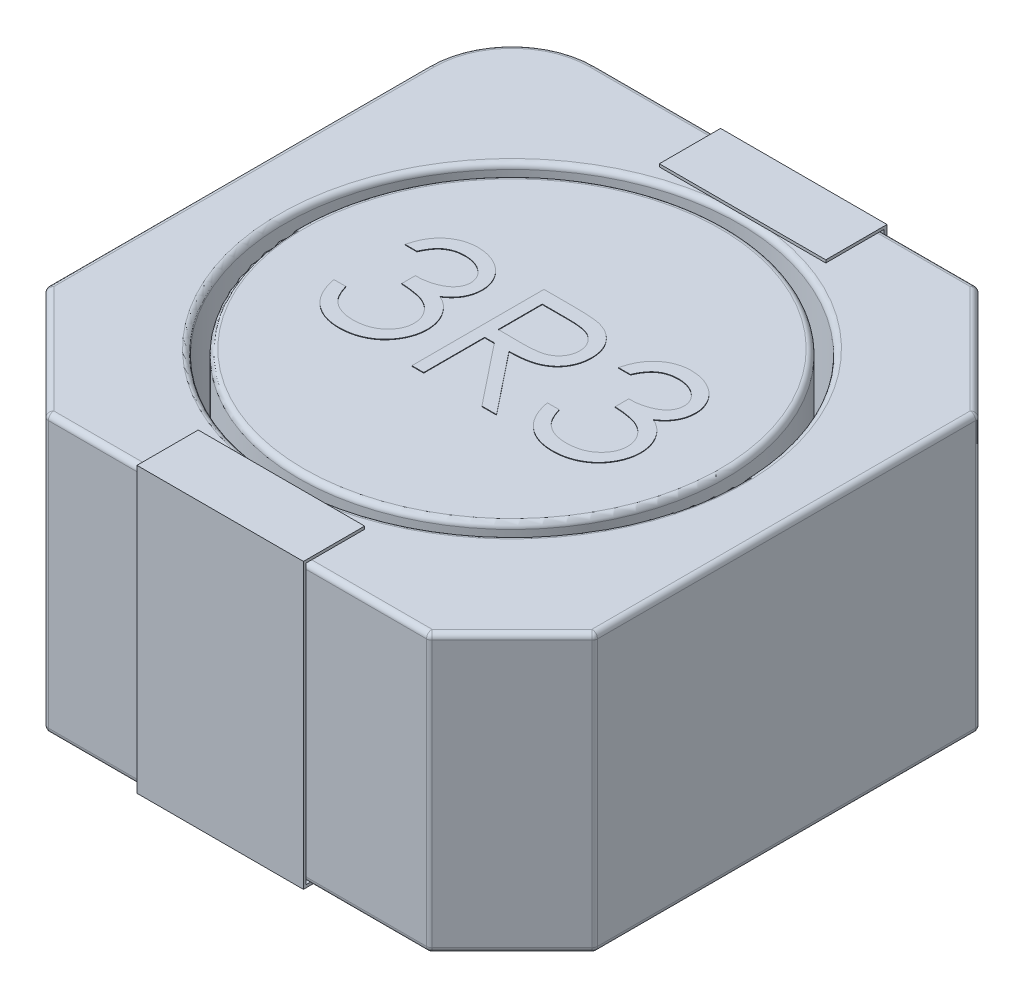
from build123d import *

# Parameters (mm, degrees)
EXTRUDE_1_DEPTH     = 5
SKETCH_2_R          = 4.1
SKETCH_2_R_2        = 3.85
CUT_EXTRUDE_1_DEPTH = 3.5
EXTRUDE_2_DEPTH     = 1.5
EXTRUDE_2_2_DEPTH   = 1.5
FILLET_1_R          = 0.1
FILLET_2_R          = 0.1
FILLET_3_R          = 0.1
FILLET_4_R          = 0.1
FILLET_5_R          = 0.1
EXTRUDE_3_DEPTH     = 0.01


with BuildPart() as part:
    # 草图1 → 凸台-拉伸1 (new body)
    with BuildSketch(Plane(origin=(0, 0, 0), x_dir=(1, 0, 0), z_dir=(0, 1, 0))):
        with BuildLine():
            Line((5.2, -3.7), (3.7, -5.2))
            Line((3.7, -5.2), (-3.2, -5.2))
            Line((-3.2, -5.2), (-5.2, -3.2))
            Line((-5.2, -3.2), (-5.2, 3.7))
            ThreePointArc((-5.2, 3.7), (-4.760660172, 4.760660172), (-3.7, 5.2))
            Line((-3.7, 5.2), (3.2, 5.2))
            Line((3.2, 5.2), (5.2, 3.2))
            Line((5.2, 3.2), (5.2, -3.7))
        make_face()
    extrude(amount=EXTRUDE_1_DEPTH)

    # 草图2 → 切除-拉伸1 (cut)
    with BuildSketch(Plane(origin=(0, 5, 0), x_dir=(1, 0, 0), z_dir=(0, 1, 0))):
        Circle(SKETCH_2_R)
        Circle(SKETCH_2_R_2, mode=Mode.SUBTRACT)
    extrude(amount=-CUT_EXTRUDE_1_DEPTH, mode=Mode.SUBTRACT)

    # 圆角1
    fillet_1_edges = [part.edges().sort_by_distance(p)[0] for p in [
        (-4.2, 5, 4.2),
        (0.25, 5, 5.2),
        (4.45, 5, 4.45),
        (5.2, 5, 0.25),
        (4.2, 5, -4.2),
        (-0.25, 5, -5.2),
        (-4.1, 5, 0),
        (-4.760660172, 5, -4.760660172),
        (-5.2, 5, -0.25),
    ]]
    fillet(fillet_1_edges, radius=FILLET_1_R)

    # 圆角2
    fillet_2_edges = [part.edges().sort_by_distance(p)[0] for p in [
        (-3.85, 5, 0),
    ]]
    fillet(fillet_2_edges, radius=FILLET_2_R)

    # 圆角3
    fillet_3_edges = [part.edges().sort_by_distance(p)[0] for p in [
        (-5.2, 0, -0.25),
        (-4.760660172, 0, -4.760660172),
        (-0.25, 0, -5.2),
        (4.2, 0, -4.2),
        (5.2, 0, 0.25),
        (4.45, 0, 4.45),
        (0.25, 0, 5.2),
        (-4.2, 0, 4.2),
    ]]
    fillet(fillet_3_edges, radius=FILLET_3_R)

    # 圆角4
    fillet_4_edges = [part.edges().sort_by_distance(p)[0] for p in [
        (5.2, 2.5, 3.7),
        (3.7, 2.5, 5.2),
        (-3.2, 2.5, 5.2),
        (-5.2, 2.5, 3.2),
        (3.687283915, 4.972093128, 5.169300656),
        (-3.187283915, 4.972093128, 5.169300656),
        (5.169300656, 4.972093128, 3.687283915),
        (-5.169300656, 4.972093128, 3.187283915),
        (5.169300656, 0.027906872, 3.687283915),
        (3.687283915, 0.027906872, 5.169300656),
        (-3.187283915, 0.027906872, 5.169300656),
        (-5.169300656, 0.027906872, 3.187283915),
    ]]
    fillet(fillet_4_edges, radius=FILLET_4_R)

    # 圆角5
    fillet_5_edges = [part.edges().sort_by_distance(p)[0] for p in [
        (3.2, 2.5, -5.2),
        (5.2, 2.5, -3.2),
        (5.169300656, 4.972093128, -3.187283915),
        (3.187283915, 4.972093128, -5.169300656),
        (5.169300656, 0.027906872, -3.187283915),
        (3.187283915, 0.027906872, -5.169300656),
    ]]
    fillet(fillet_5_edges, radius=FILLET_5_R)

    # 草图4 → 凸台-拉伸3 (add)
    with BuildSketch(Plane(origin=(0, 5, 0), x_dir=(1, 0, 0), z_dir=(0, 1, 0))):
        with BuildLine():
            Line((-2.368651512, 0.655484103), (-2.582353435, 0.655484103))
            add(Edge.make_bspline(
                [(-2.582353435, 0.655484103), (-2.576563902, 0.679454775), (-2.565245837, 0.726315479), (-2.541639095, 0.793267562), (-2.515922102, 0.856624815), (-2.4850413, 0.915200893), (-2.451357666, 0.970173004), (-2.412765957, 1.020294319), (-2.371046646, 1.066839569), (-2.324901457, 1.108146253), (-2.276508564, 1.145550744), (-2.225186082, 1.177442524), (-2.171966577, 1.20487735), (-2.116481321, 1.227478972), (-2.058565122, 1.244505266), (-1.998741575, 1.256858378), (-1.936853908, 1.264880547), (-1.894843493, 1.265663477), (-1.873511789, 1.266061026)],
                knots=[0, 0, 0, 0, 7.3931e-05, 0.000144529, 0.000212742, 0.000278882, 0.000342945, 0.000405913, 0.000468387, 0.000530188, 0.000591439, 0.00065166, 0.000711181, 0.000770884, 0.000831103, 0.000892006, 0.000954012, 0.001017976, 0.001017976, 0.001017976, 0.001017976], degree=3))
            add(Edge.make_bspline(
                [(-1.873511789, 1.266061026), (-1.842431209, 1.265122657), (-1.780948007, 1.263266387), (-1.69062172, 1.246315673), (-1.603517759, 1.219492502), (-1.520589538, 1.182430913), (-1.443560569, 1.136719544), (-1.375023985, 1.082314965), (-1.315908766, 1.020266868), (-1.266314555, 0.951732749), (-1.227483172, 0.878488554), (-1.198849407, 0.803104876), (-1.181417513, 0.725760534), (-1.179158349, 0.673538171), (-1.178026512, 0.647374879)],
                knots=[0, 0, 0, 0, 9.3165e-05, 0.000184299, 0.000274676, 0.00036607, 0.000456139, 0.000542705, 0.000627729, 0.00071246, 0.000795685, 0.000875689, 0.000953816, 0.001032256, 0.001032256, 0.001032256, 0.001032256], degree=3))
            add(Edge.make_bspline(
                [(-1.178026512, 0.647374879), (-1.17881817, 0.622197041), (-1.180367321, 0.572927921), (-1.193521145, 0.500999546), (-1.215657424, 0.433207671), (-1.246320959, 0.369266916), (-1.286014049, 0.309582695), (-1.334096724, 0.254020723), (-1.390908356, 0.202334563), (-1.433960633, 0.172725779), (-1.45612522, 0.1574823)],
                knots=[0, 0, 0, 0, 7.549e-05, 0.000147723, 0.00021847, 0.000288876, 0.000359789, 0.000432846, 0.000508829, 0.000589457, 0.000589457, 0.000589457, 0.000589457], degree=3))
            add(Edge.make_bspline(
                [(-1.45612522, 0.1574823), (-1.43079433, 0.145250723), (-1.38060651, 0.12101643), (-1.312196239, 0.073489567), (-1.250094685, 0.018614445), (-1.215461976, -0.024209039), (-1.198061068, -0.045725332)],
                knots=[0, 0, 0, 0, 8.4271e-05, 0.000166965, 0.000249046, 0.000331932, 0.000331932, 0.000331932, 0.000331932], degree=3))
            add(Edge.make_bspline(
                [(-1.198061068, -0.045725332), (-1.18660294, -0.061412838), (-1.16387432, -0.092530956), (-1.13581943, -0.142561989), (-1.110367872, -0.193147555), (-1.090535312, -0.245643509), (-1.07517702, -0.299441398), (-1.064198755, -0.3546336), (-1.05737876, -0.411265183), (-1.056402071, -0.449577781), (-1.055911128, -0.468836059)],
                knots=[0, 0, 0, 0, 5.8227e-05, 0.0001155, 0.00017182, 0.000227986, 0.00028355, 0.000339493, 0.000396649, 0.000454416, 0.000454416, 0.000454416, 0.000454416], degree=3))
            add(Edge.make_bspline(
                [(-1.055911128, -0.468836059), (-1.057132038, -0.502180173), (-1.059568112, -0.568711483), (-1.081342313, -0.667005892), (-1.115097036, -0.763089671), (-1.163032915, -0.854988802), (-1.221453488, -0.940972597), (-1.290956953, -1.017904872), (-1.370753599, -1.084034637), (-1.459748157, -1.139286595), (-1.556166417, -1.183453967), (-1.659291954, -1.214109121), (-1.767638866, -1.234074881), (-1.841938831, -1.236215876), (-1.879712961, -1.237304358)],
                knots=[0, 0, 0, 0, 9.9919e-05, 0.000199368, 0.000300604, 0.000404715, 0.000509373, 0.0006117, 0.000714673, 0.000819238, 0.000925117, 0.001031803, 0.001141284, 0.001254506, 0.001254506, 0.001254506, 0.001254506], degree=3))
            add(Edge.make_bspline(
                [(-1.879712961, -1.237304358), (-1.905171449, -1.236713663), (-1.955265264, -1.235551372), (-2.028909502, -1.227605752), (-2.099205158, -1.213093731), (-2.166247277, -1.193565232), (-2.230095418, -1.168805851), (-2.290554747, -1.137972951), (-2.347997228, -1.101702089), (-2.4018808, -1.059565131), (-2.45219904, -1.012429076), (-2.497614732, -0.959457143), (-2.538885056, -0.901628552), (-2.574904958, -0.838271615), (-2.607315099, -0.77020511), (-2.633972143, -0.696557471), (-2.657434646, -0.617987092), (-2.668343128, -0.563233486), (-2.673939974, -0.535140897)],
                knots=[0, 0, 0, 0, 7.6376e-05, 0.000150282, 0.000221848, 0.000291435, 0.000359554, 0.000426967, 0.000494723, 0.000563043, 0.000631881, 0.000701213, 0.000772025, 0.000844681, 0.000919578, 0.000997909, 0.001079421, 0.00116531, 0.00116531, 0.00116531, 0.00116531], degree=3))
            Line((-2.673939974, -0.535140897), (-2.460238051, -0.535140897))
            add(Edge.make_bspline(
                [(-2.460238051, -0.535140897), (-2.45467049, -0.55347585), (-2.443841101, -0.589138928), (-2.425407301, -0.640465279), (-2.404405852, -0.687517454), (-2.381876126, -0.730640614), (-2.358214361, -0.770259445), (-2.331738314, -0.805326324), (-2.304408949, -0.837381488), (-2.283808175, -0.855441304), (-2.273725881, -0.864280019)],
                knots=[0, 0, 0, 0, 5.7482e-05, 0.000111807, 0.000163485, 0.000211918, 0.000257731, 0.000301712, 0.000343624, 0.000383798, 0.000383798, 0.000383798, 0.000383798], degree=3))
            add(Edge.make_bspline(
                [(-2.273725881, -0.864280019), (-2.26039321, -0.874559082), (-2.233769024, -0.895085479), (-2.190383852, -0.921280337), (-2.144755778, -0.943977749), (-2.095896151, -0.961315763), (-2.044859317, -0.975996279), (-1.990820341, -0.985603275), (-1.934255981, -0.992194691), (-1.895633628, -0.99277635), (-1.875896855, -0.993073589)],
                knots=[0, 0, 0, 0, 5.0469e-05, 0.000100782, 0.000151769, 0.000203078, 0.000256087, 0.000310912, 0.00036754, 0.000426721, 0.000426721, 0.000426721, 0.000426721], degree=3))
            add(Edge.make_bspline(
                [(-1.875896855, -0.993073589), (-1.853612775, -0.992654553), (-1.810038182, -0.991835166), (-1.746455501, -0.984299729), (-1.685966684, -0.973325287), (-1.629243318, -0.956375562), (-1.575542384, -0.935433589), (-1.525616654, -0.909138871), (-1.478810732, -0.878288265), (-1.435724119, -0.843223231), (-1.396980836, -0.804836464), (-1.36286806, -0.764686499), (-1.333868067, -0.722942622), (-1.310474954, -0.679373829), (-1.292002883, -0.63416054), (-1.279427705, -0.587175872), (-1.270684085, -0.538804339), (-1.269972015, -0.50592338), (-1.269613051, -0.489347627)],
                knots=[0, 0, 0, 0, 6.6824e-05, 0.000130669, 0.000191854, 0.000251023, 0.000307979, 0.000364521, 0.000419955, 0.000475904, 0.000530885, 0.00058335, 0.000633762, 0.000683063, 0.000731428, 0.000779917, 0.000828773, 0.00087844, 0.00087844, 0.00087844, 0.00087844], degree=3))
            add(Edge.make_bspline(
                [(-1.269613051, -0.489347627), (-1.270654202, -0.46716027), (-1.272731325, -0.422895957), (-1.288589483, -0.357773821), (-1.314673604, -0.295028964), (-1.35119008, -0.2357319), (-1.39564171, -0.180775438), (-1.447597119, -0.13174109), (-1.507487753, -0.091280189), (-1.5626102, -0.063325228), (-1.611436137, -0.044250004), (-1.653220532, -0.031544358), (-1.699999579, -0.020785425), (-1.751207577, -0.010775826), (-1.807230372, -0.002256837), (-1.868006974, 0.004847327), (-1.933549697, 0.010531739), (-1.978923508, 0.013070216), (-2.002305358, 0.014378334)],
                knots=[0, 0, 0, 0, 6.6512e-05, 0.000132693, 0.000199842, 0.000269625, 0.000340845, 0.00041138, 0.000483093, 0.000556905, 0.000596324, 0.000640233, 0.000687786, 0.000740268, 0.000796736, 0.000857737, 0.000923814, 0.000994066, 0.000994066, 0.000994066, 0.000994066], degree=3))
            Line((-2.002305358, 0.014378334), (-2.002305358, 0.258609103))
            add(Edge.make_bspline(
                [(-2.002305358, 0.258609103), (-1.972845101, 0.259109032), (-1.915139694, 0.26008827), (-1.830847319, 0.271931934), (-1.750243155, 0.288315362), (-1.675113532, 0.313410466), (-1.606636461, 0.342557168), (-1.547227946, 0.376474475), (-1.497720297, 0.414176295), (-1.458354104, 0.456244553), (-1.428738682, 0.501362469), (-1.407085094, 0.54838648), (-1.394294157, 0.597728743), (-1.392586687, 0.631402794), (-1.391728435, 0.648328905)],
                knots=[0, 0, 0, 0, 8.8311e-05, 0.000172979, 0.000254936, 0.000334734, 0.000410148, 0.000477894, 0.000539436, 0.000596138, 0.000649853, 0.000700661, 0.000750872, 0.000801617, 0.000801617, 0.000801617, 0.000801617], degree=3))
            add(Edge.make_bspline(
                [(-1.391728435, 0.648328905), (-1.392010383, 0.660764299), (-1.392571304, 0.685503927), (-1.399645166, 0.721647947), (-1.410275094, 0.756686983), (-1.424888981, 0.790472029), (-1.444449384, 0.822768769), (-1.467857743, 0.853852551), (-1.495730683, 0.883545908), (-1.527670353, 0.911223054), (-1.561968384, 0.937599982), (-1.599557964, 0.95999301), (-1.639305703, 0.979141704), (-1.68125561, 0.994932454), (-1.725543819, 1.006811006), (-1.771962244, 1.015339855), (-1.820599401, 1.020672259), (-1.853781597, 1.021439985), (-1.870649709, 1.021830257)],
                knots=[0, 0, 0, 0, 3.7256e-05, 7.4119e-05, 0.000110031, 0.000146987, 0.000184209, 0.000223038, 0.000263537, 0.000306122, 0.000349721, 0.000393161, 0.000437111, 0.000481942, 0.000527419, 0.000574479, 0.000623416, 0.000674016, 0.000674016, 0.000674016, 0.000674016], degree=3))
            add(Edge.make_bspline(
                [(-1.870649709, 1.021830257), (-1.897763076, 1.020883634), (-1.950721788, 1.019034659), (-2.027068008, 1.002840109), (-2.098042412, 0.977001448), (-2.152293184, 0.946158805), (-2.192354364, 0.915712528), (-2.220981709, 0.889122547), (-2.249094414, 0.859572715), (-2.27484299, 0.825242999), (-2.300882964, 0.788458272), (-2.32458971, 0.747348589), (-2.347626393, 0.702986313), (-2.361507414, 0.671624819), (-2.368651512, 0.655484103)],
                knots=[0, 0, 0, 0, 8.1262e-05, 0.000158723, 0.000232978, 0.000307113, 0.000344894, 0.00038372, 0.000424218, 0.000467059, 0.000512313, 0.000559354, 0.000609276, 0.000662216, 0.000662216, 0.000662216, 0.000662216], degree=3))
        make_face()
        with BuildLine():
            Line((-0.628507282, 1.205003334), (-0.151971074, 1.205003334))
            add(Edge.make_bspline(
                [(-0.151971074, 1.205003334), (-0.120170413, 1.20489748), (-0.059109622, 1.204694229), (0.028366121, 1.203560915), (0.107850271, 1.200312648), (0.179301269, 1.197517344), (0.242717804, 1.192420148), (0.298294335, 1.187548351), (0.345774894, 1.181170913), (0.374517161, 1.175248117), (0.38753088, 1.172566435)],
                knots=[0, 0, 0, 0, 9.5404e-05, 0.000183186, 0.000262422, 0.000334052, 0.000397674, 0.000453255, 0.000501422, 0.000541275, 0.000541275, 0.000541275, 0.000541275], degree=3))
            add(Edge.make_bspline(
                [(0.38753088, 1.172566435), (0.404952529, 1.168261975), (0.439424177, 1.159744881), (0.489056276, 1.141742902), (0.536350843, 1.120910622), (0.58111142, 1.096442448), (0.623113806, 1.06815675), (0.662791085, 1.036541831), (0.700323302, 1.001770678), (0.73419259, 0.962966616), (0.766127909, 0.92225642), (0.793062314, 0.878234757), (0.816280508, 0.832200753), (0.834766164, 0.783686242), (0.849650999, 0.733161715), (0.860146351, 0.680169516), (0.866440463, 0.624951067), (0.867081261, 0.587287918), (0.86740618, 0.568190684)],
                knots=[0, 0, 0, 0, 5.3803e-05, 0.000106459, 0.000158137, 0.000208732, 0.000259271, 0.000309854, 0.000360814, 0.00041251, 0.000464222, 0.000515847, 0.000567046, 0.000618691, 0.000671372, 0.000724883, 0.000780563, 0.000837836, 0.000837836, 0.000837836, 0.000837836], degree=3))
            add(Edge.make_bspline(
                [(0.86740618, 0.568190684), (0.866406737, 0.536462157), (0.864456564, 0.474551584), (0.846273949, 0.38470302), (0.816490281, 0.30089029), (0.7754489, 0.223218924), (0.723184221, 0.153202931), (0.66037039, 0.091705139), (0.586972365, 0.040242984), (0.518644563, 0.004556344), (0.458287223, -0.018298831), (0.408598487, -0.034379997), (0.35439649, -0.046804655), (0.296200553, -0.057935388), (0.233768495, -0.066338951), (0.16724995, -0.072493866), (0.096597479, -0.076340639), (0.048061434, -0.076913503), (0.023092779, -0.077208204)],
                knots=[0, 0, 0, 0, 9.5098e-05, 0.000185561, 0.000273673, 0.000361163, 0.000448075, 0.000534767, 0.000623712, 0.000716091, 0.000765168, 0.000817215, 0.000872634, 0.000931855, 0.000994931, 0.001061525, 0.001132226, 0.001207131, 0.001207131, 0.001207131, 0.001207131], degree=3))
            Line((0.023092779, -0.077208204), (0.897935026, -1.176246666))
            Line((0.897935026, -1.176246666), (0.633669702, -1.176246666))
            Line((0.633669702, -1.176246666), (-0.241172546, -0.077208204))
            Line((-0.241172546, -0.077208204), (-0.414805358, -0.077208204))
            Line((-0.414805358, -0.077208204), (-0.414805358, -1.176246666))
            Line((-0.414805358, -1.176246666), (-0.628507282, -1.176246666))
            Line((-0.628507282, -1.176246666), (-0.628507282, 1.205003334))
        make_face()
        with BuildLine():
            Line((-0.414805358, 0.960772565), (-0.414805358, 0.167022565))
            Line((-0.414805358, 0.167022565), (0.021184726, 0.163683472))
            add(Edge.make_bspline(
                [(0.021184726, 0.163683472), (0.041541038, 0.163674467), (0.080997369, 0.163657011), (0.138079785, 0.166374205), (0.191229361, 0.169465284), (0.240242802, 0.174193321), (0.285142002, 0.180286649), (0.325904521, 0.187908679), (0.362596897, 0.196788743), (0.405390367, 0.210533063), (0.453176293, 0.232308587), (0.505108947, 0.263989756), (0.549333751, 0.303837675), (0.586697511, 0.349403544), (0.616721285, 0.399502492), (0.637888594, 0.453533986), (0.651320505, 0.510133984), (0.652904748, 0.549035518), (0.653704257, 0.568667697)],
                knots=[0, 0, 0, 0, 6.106e-05, 0.000118351, 0.000171404, 0.000220768, 0.000266034, 0.000307292, 0.000345124, 0.000379216, 0.000441986, 0.000502207, 0.000560994, 0.000619628, 0.000678448, 0.000735404, 0.000793147, 0.000851976, 0.000851976, 0.000851976, 0.000851976], degree=3))
            add(Edge.make_bspline(
                [(0.653704257, 0.568667697), (0.652886385, 0.58781742), (0.651265662, 0.625765182), (0.638033553, 0.681320364), (0.615657028, 0.733753414), (0.585502077, 0.782851037), (0.548763366, 0.827418332), (0.50568464, 0.865550413), (0.457443784, 0.897016566), (0.412355701, 0.9171241), (0.372055281, 0.929452072), (0.337064745, 0.938127417), (0.297528186, 0.945097315), (0.253253633, 0.950681728), (0.204430094, 0.955481609), (0.150810705, 0.958714516), (0.092751217, 0.960628949), (0.05251018, 0.960723579), (0.031679017, 0.960772565)],
                knots=[0, 0, 0, 0, 5.7402e-05, 0.000113751, 0.000170185, 0.00022778, 0.000286046, 0.000342812, 0.000399705, 0.000458213, 0.000490197, 0.000526062, 0.000566296, 0.000610553, 0.000659916, 0.000713446, 0.000771673, 0.000834163, 0.000834163, 0.000834163, 0.000834163], degree=3))
            Line((0.031679017, 0.960772565), (-0.414805358, 0.960772565))
        make_face(mode=Mode.SUBTRACT)
        with BuildLine():
            Line((1.477983103, 0.655484103), (1.26428118, 0.655484103))
            add(Edge.make_bspline(
                [(1.26428118, 0.655484103), (1.270070714, 0.679454775), (1.281388778, 0.726315479), (1.30499552, 0.793267562), (1.330712513, 0.856624815), (1.361593315, 0.915200893), (1.395276949, 0.970173004), (1.433868658, 1.020294319), (1.475587969, 1.066839569), (1.521733158, 1.108146253), (1.570126051, 1.145550744), (1.621448534, 1.177442524), (1.674668038, 1.20487735), (1.730153295, 1.227478972), (1.788069494, 1.244505266), (1.847893041, 1.256858378), (1.909780708, 1.264880547), (1.951791122, 1.265663477), (1.973122827, 1.266061026)],
                knots=[0, 0, 0, 0, 7.3931e-05, 0.000144529, 0.000212742, 0.000278882, 0.000342945, 0.000405913, 0.000468387, 0.000530188, 0.000591439, 0.00065166, 0.000711181, 0.000770884, 0.000831103, 0.000892006, 0.000954012, 0.001017976, 0.001017976, 0.001017976, 0.001017976], degree=3))
            add(Edge.make_bspline(
                [(1.973122827, 1.266061026), (2.004203406, 1.265122657), (2.065686609, 1.263266387), (2.156012896, 1.246315673), (2.243116857, 1.219492502), (2.326045077, 1.182430913), (2.403074046, 1.136719544), (2.471610631, 1.082314965), (2.53072585, 1.020266868), (2.58032006, 0.951732749), (2.619151443, 0.878488554), (2.647785208, 0.803104876), (2.665217102, 0.725760534), (2.667476266, 0.673538171), (2.668608103, 0.647374879)],
                knots=[0, 0, 0, 0, 9.3165e-05, 0.000184299, 0.000274676, 0.00036607, 0.000456139, 0.000542705, 0.000627729, 0.00071246, 0.000795685, 0.000875689, 0.000953816, 0.001032256, 0.001032256, 0.001032256, 0.001032256], degree=3))
            add(Edge.make_bspline(
                [(2.668608103, 0.647374879), (2.667816446, 0.622197041), (2.666267295, 0.572927921), (2.65311347, 0.500999546), (2.630977191, 0.433207671), (2.600313656, 0.369266916), (2.560620566, 0.309582695), (2.512537892, 0.254020723), (2.455726259, 0.202334563), (2.412673982, 0.172725779), (2.390509395, 0.1574823)],
                knots=[0, 0, 0, 0, 7.549e-05, 0.000147723, 0.00021847, 0.000288876, 0.000359789, 0.000432846, 0.000508829, 0.000589457, 0.000589457, 0.000589457, 0.000589457], degree=3))
            add(Edge.make_bspline(
                [(2.390509395, 0.1574823), (2.415840285, 0.145250723), (2.466028105, 0.12101643), (2.534438376, 0.073489567), (2.596539931, 0.018614445), (2.631172639, -0.024209039), (2.648573548, -0.045725332)],
                knots=[0, 0, 0, 0, 8.4271e-05, 0.000166965, 0.000249046, 0.000331932, 0.000331932, 0.000331932, 0.000331932], degree=3))
            add(Edge.make_bspline(
                [(2.648573548, -0.045725332), (2.660031675, -0.061412838), (2.682760296, -0.092530956), (2.710815186, -0.142561989), (2.736266744, -0.193147555), (2.756099304, -0.245643509), (2.771457595, -0.299441398), (2.78243586, -0.3546336), (2.789255856, -0.411265183), (2.790232544, -0.449577781), (2.790723488, -0.468836059)],
                knots=[0, 0, 0, 0, 5.8227e-05, 0.0001155, 0.00017182, 0.000227986, 0.00028355, 0.000339493, 0.000396649, 0.000454416, 0.000454416, 0.000454416, 0.000454416], degree=3))
            add(Edge.make_bspline(
                [(2.790723488, -0.468836059), (2.789502578, -0.502180173), (2.787066503, -0.568711483), (2.765292302, -0.667005892), (2.73153758, -0.763089671), (2.6836017, -0.854988802), (2.625181127, -0.940972597), (2.555677662, -1.017904872), (2.475881016, -1.084034637), (2.386886459, -1.139286595), (2.290468198, -1.183453967), (2.187342661, -1.214109121), (2.07899575, -1.234074881), (2.004695785, -1.236215876), (1.966921655, -1.237304358)],
                knots=[0, 0, 0, 0, 9.9919e-05, 0.000199368, 0.000300604, 0.000404715, 0.000509373, 0.0006117, 0.000714673, 0.000819238, 0.000925117, 0.001031803, 0.001141284, 0.001254506, 0.001254506, 0.001254506, 0.001254506], degree=3))
            add(Edge.make_bspline(
                [(1.966921655, -1.237304358), (1.941463167, -1.236713663), (1.891369351, -1.235551372), (1.817725114, -1.227605752), (1.747429458, -1.213093731), (1.680387338, -1.193565232), (1.616539198, -1.168805851), (1.556079869, -1.137972951), (1.498637388, -1.101702089), (1.444753816, -1.059565131), (1.394435576, -1.012429076), (1.349019883, -0.959457143), (1.30774956, -0.901628552), (1.271729657, -0.838271615), (1.239319516, -0.77020511), (1.212662473, -0.696557471), (1.18919997, -0.617987092), (1.178291488, -0.563233486), (1.172694642, -0.535140897)],
                knots=[0, 0, 0, 0, 7.6376e-05, 0.000150282, 0.000221848, 0.000291435, 0.000359554, 0.000426967, 0.000494723, 0.000563043, 0.000631881, 0.000701213, 0.000772025, 0.000844681, 0.000919578, 0.000997909, 0.001079421, 0.00116531, 0.00116531, 0.00116531, 0.00116531], degree=3))
            Line((1.172694642, -0.535140897), (1.386396565, -0.535140897))
            add(Edge.make_bspline(
                [(1.386396565, -0.535140897), (1.391964125, -0.55347585), (1.402793515, -0.589138928), (1.421227314, -0.640465279), (1.442228763, -0.687517454), (1.46475849, -0.730640614), (1.488420254, -0.770259445), (1.514896301, -0.805326324), (1.542225666, -0.837381488), (1.56282644, -0.855441304), (1.572908734, -0.864280019)],
                knots=[0, 0, 0, 0, 5.7482e-05, 0.000111807, 0.000163485, 0.000211918, 0.000257731, 0.000301712, 0.000343624, 0.000383798, 0.000383798, 0.000383798, 0.000383798], degree=3))
            add(Edge.make_bspline(
                [(1.572908734, -0.864280019), (1.586241405, -0.874559082), (1.612865592, -0.895085479), (1.656250763, -0.921280337), (1.701878837, -0.943977749), (1.750738464, -0.961315763), (1.801775299, -0.975996279), (1.855814274, -0.985603275), (1.912378634, -0.992194691), (1.951000988, -0.99277635), (1.970737761, -0.993073589)],
                knots=[0, 0, 0, 0, 5.0469e-05, 0.000100782, 0.000151769, 0.000203078, 0.000256087, 0.000310912, 0.00036754, 0.000426721, 0.000426721, 0.000426721, 0.000426721], degree=3))
            add(Edge.make_bspline(
                [(1.970737761, -0.993073589), (1.99302184, -0.992654553), (2.036596434, -0.991835166), (2.100179115, -0.984299729), (2.160667932, -0.973325287), (2.217391297, -0.956375562), (2.271092232, -0.935433589), (2.321017961, -0.909138871), (2.367823884, -0.878288265), (2.410910497, -0.843223231), (2.44965378, -0.804836464), (2.483766556, -0.764686499), (2.512766549, -0.722942622), (2.536159662, -0.679373829), (2.554631732, -0.63416054), (2.56720691, -0.587175872), (2.57595053, -0.538804339), (2.5766626, -0.50592338), (2.577021565, -0.489347627)],
                knots=[0, 0, 0, 0, 6.6824e-05, 0.000130669, 0.000191854, 0.000251023, 0.000307979, 0.000364521, 0.000419955, 0.000475904, 0.000530885, 0.00058335, 0.000633762, 0.000683063, 0.000731428, 0.000779917, 0.000828773, 0.00087844, 0.00087844, 0.00087844, 0.00087844], degree=3))
            add(Edge.make_bspline(
                [(2.577021565, -0.489347627), (2.575980413, -0.46716027), (2.573903291, -0.422895957), (2.558045132, -0.357773821), (2.531961012, -0.295028964), (2.495444535, -0.2357319), (2.450992906, -0.180775438), (2.399037496, -0.13174109), (2.339146862, -0.091280189), (2.284024415, -0.063325228), (2.235198479, -0.044250004), (2.193414083, -0.031544358), (2.146635037, -0.020785425), (2.095427039, -0.010775826), (2.039404243, -0.002256837), (1.978627642, 0.004847327), (1.913084918, 0.010531739), (1.867711107, 0.013070216), (1.844329257, 0.014378334)],
                knots=[0, 0, 0, 0, 6.6512e-05, 0.000132693, 0.000199842, 0.000269625, 0.000340845, 0.00041138, 0.000483093, 0.000556905, 0.000596324, 0.000640233, 0.000687786, 0.000740268, 0.000796736, 0.000857737, 0.000923814, 0.000994066, 0.000994066, 0.000994066, 0.000994066], degree=3))
            Line((1.844329257, 0.014378334), (1.844329257, 0.258609103))
            add(Edge.make_bspline(
                [(1.844329257, 0.258609103), (1.873789514, 0.259109032), (1.931494922, 0.26008827), (2.015787297, 0.271931934), (2.096391461, 0.288315362), (2.171521084, 0.313410466), (2.239998155, 0.342557168), (2.29940667, 0.376474475), (2.348914318, 0.414176295), (2.388280511, 0.456244553), (2.417895933, 0.501362469), (2.439549522, 0.54838648), (2.452340458, 0.597728743), (2.454047928, 0.631402794), (2.45490618, 0.648328905)],
                knots=[0, 0, 0, 0, 8.8311e-05, 0.000172979, 0.000254936, 0.000334734, 0.000410148, 0.000477894, 0.000539436, 0.000596138, 0.000649853, 0.000700661, 0.000750872, 0.000801617, 0.000801617, 0.000801617, 0.000801617], degree=3))
            add(Edge.make_bspline(
                [(2.45490618, 0.648328905), (2.454624233, 0.660764299), (2.454063311, 0.685503927), (2.446989449, 0.721647947), (2.436359521, 0.756686983), (2.421745634, 0.790472029), (2.402185231, 0.822768769), (2.378776872, 0.853852551), (2.350903933, 0.883545908), (2.318964262, 0.911223054), (2.284666231, 0.937599982), (2.247076652, 0.95999301), (2.207328912, 0.979141704), (2.165379006, 0.994932454), (2.121090797, 1.006811006), (2.074672371, 1.015339855), (2.026035215, 1.020672259), (1.992853019, 1.021439985), (1.975984906, 1.021830257)],
                knots=[0, 0, 0, 0, 3.7256e-05, 7.4119e-05, 0.000110031, 0.000146987, 0.000184209, 0.000223038, 0.000263537, 0.000306122, 0.000349721, 0.000393161, 0.000437111, 0.000481942, 0.000527419, 0.000574479, 0.000623416, 0.000674016, 0.000674016, 0.000674016, 0.000674016], degree=3))
            add(Edge.make_bspline(
                [(1.975984906, 1.021830257), (1.948871539, 1.020883634), (1.895912827, 1.019034659), (1.819566607, 1.002840109), (1.748592203, 0.977001448), (1.694341432, 0.946158805), (1.654280252, 0.915712528), (1.625652906, 0.889122547), (1.597540202, 0.859572715), (1.571791625, 0.825242999), (1.545751652, 0.788458272), (1.522044905, 0.747348589), (1.499008222, 0.702986313), (1.485127202, 0.671624819), (1.477983103, 0.655484103)],
                knots=[0, 0, 0, 0, 8.1262e-05, 0.000158723, 0.000232978, 0.000307113, 0.000344894, 0.00038372, 0.000424218, 0.000467059, 0.000512313, 0.000559354, 0.000609276, 0.000662216, 0.000662216, 0.000662216, 0.000662216], degree=3))
        make_face()
    extrude(amount=EXTRUDE_3_DEPTH)


with BuildPart() as body_2:
    # 草图3 → 凸台-拉伸2 (new body, symmetric)
    with BuildSketch(Plane(origin=(0, 0, 0), x_dir=(0, 0, -1), z_dir=(1, 0, 0))):
        Polygon((-4.15635489, 5.01), (-5.21, 5.01), (-5.21, -0.01), (-4.02816107, -0.01), (-4.02816107, -0.06), (-5.26, -0.06), (-5.26, 5.06), (-4.15635489, 5.06), align=None)
    extrude(amount=EXTRUDE_2_DEPTH, both=True)


with BuildPart() as body_3:
    # 草图3 → Extrude 2 2 (new body, symmetric)
    with BuildSketch(Plane(origin=(0, 0, 0), x_dir=(0, 0, -1), z_dir=(1, 0, 0))):
        Polygon((4.15635489, 5.06), (4.15635489, 5.01), (5.21, 5.01), (5.21, -0.01), (4.02816107, -0.01), (4.02816107, -0.06), (5.26, -0.06), (5.26, 5.06), align=None)
    extrude(amount=EXTRUDE_2_2_DEPTH, both=True)


solid = Compound([part.part, body_2.part, body_3.part])
